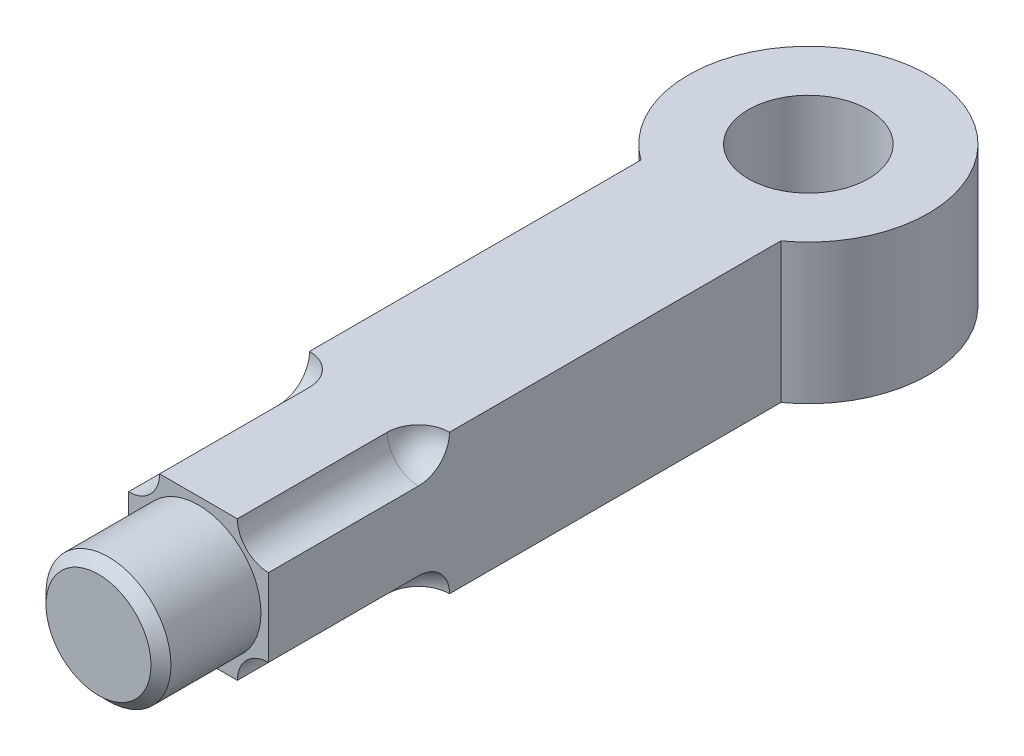
from build123d import *

# Parameters (mm, degrees)
SKETCH1_R           = 24
SKETCH1_R_2         = 12
BOSS_EXTRUDE1_DEPTH = 14
BOSS_EXTRUDE2_REACH = 148
SKETCH2_W           = 28
SKETCH2_H           = 28
SKETCH4_R           = 12.5
BOSS_EXTRUDE3_DEPTH = 20
CHAMFER1_SIZE       = 2


with BuildPart() as part:
    # Sketch1 → Boss-Extrude1 (new body, symmetric)
    with BuildSketch(Plane(origin=(0, 0, 0), x_dir=(1, 0, 0), z_dir=(0, 1, 0))):
        Circle(SKETCH1_R)
        Circle(SKETCH1_R_2, mode=Mode.SUBTRACT)
    extrude(amount=BOSS_EXTRUDE1_DEPTH, both=True)

    # Sketch2 → Boss-Extrude2 (add, up to next)
    with BuildSketch(Plane.XY.offset(122), mode=Mode.PRIVATE) as boss_extrude2_sk1:
        Rectangle(SKETCH2_W, SKETCH2_H)
    boss_extrude2_tool1 = extrude(boss_extrude2_sk1.sketch, amount=-BOSS_EXTRUDE2_REACH, mode=Mode.PRIVATE) - part.part
    add(boss_extrude2_tool1.solids().sort_by_distance((0, 0, 122))[0])

    # Sketch3 → Cut-Revolve1 (revolve, cut)
    with BuildSketch(Plane(origin=(14, 0, 0), x_dir=(0, 0, -1), z_dir=(1, 0, 0))):
        with BuildLine():
            Line((-122, 14), (-122, 7.78))
            Line((-122, 7.78), (-92, 7.78))
            ThreePointArc((-92, 7.78), (-87.601795821, 9.601795821), (-85.78, 14))
            Line((-85.78, 14), (-122, 14))
        make_face()
    cut_revolve1 = revolve(axis=Axis((14, 14, -500000), (0, 0, 1)), mode=Mode.SUBTRACT)

    # Mirror1: Cut-Revolve1 across plane
    add(cut_revolve1.mirror(Plane(origin=(0, 0, 0), x_dir=(0, 0, 1), z_dir=(1, 0, 0))), mode=Mode.SUBTRACT)

    # Mirror2: Cut-Revolve1 across plane
    add(cut_revolve1.mirror(Plane.ZX), mode=Mode.SUBTRACT)

    # Mirror2 copy 1 sketch → Mirror2 copy 1 (revolve, cut)
    with BuildSketch(Plane(origin=(-14, 0, 0), x_dir=(0, 0, -1), z_dir=(-1, 0, 0))):
        with BuildLine():
            Line((-122, 14), (-122, 7.78))
            Line((-122, 7.78), (-92, 7.78))
            ThreePointArc((-92, 7.78), (-87.601795821, 9.601795821), (-85.78, 14))
            Line((-85.78, 14), (-122, 14))
        make_face()
    revolve(axis=Axis((-14, -14, -500000), (0, 0, 1)), mode=Mode.SUBTRACT)

    # Sketch4 → Boss-Extrude3 (add)
    with BuildSketch(Plane.XY.offset(122)):
        Circle(SKETCH4_R)
    extrude(amount=BOSS_EXTRUDE3_DEPTH)

    # Chamfer1
    chamfer1_edges = [part.edges().sort_by_distance(p)[0] for p in [
        (-12.5, 0, 142),
    ]]
    chamfer(chamfer1_edges, length=CHAMFER1_SIZE)


solid = part.part
